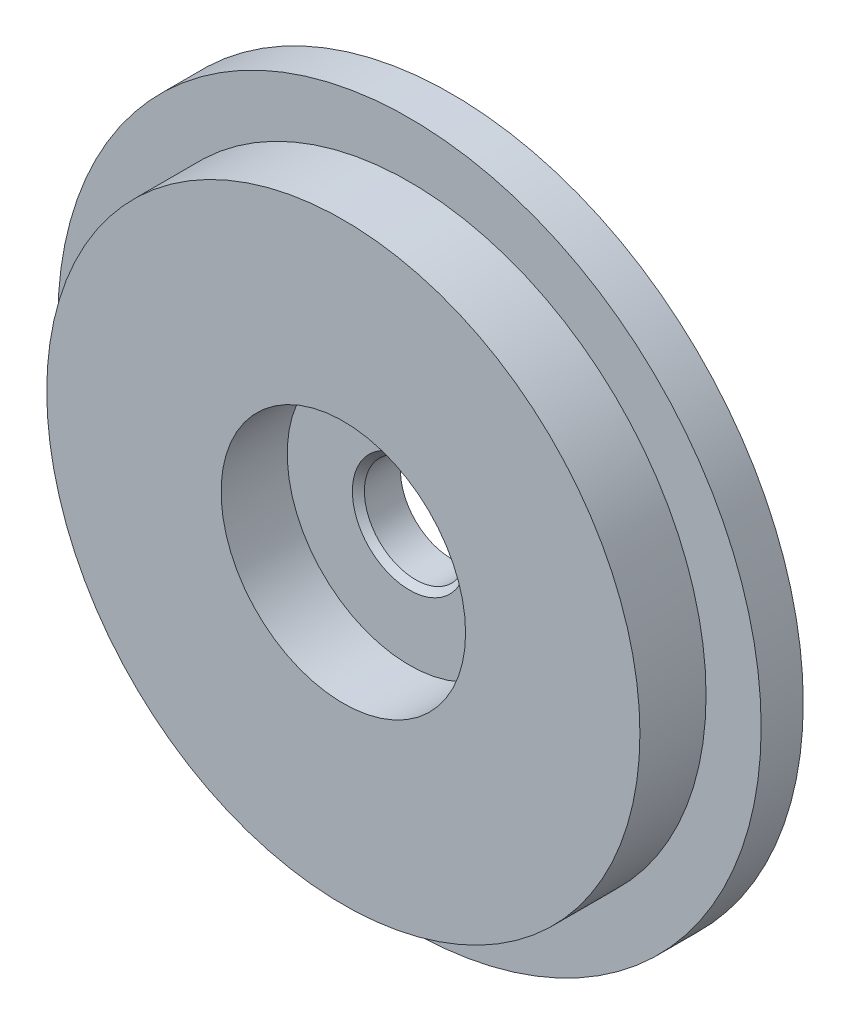
from build123d import *

# Parameters (mm, degrees)
SKETCH_1_R          = 17.55
EXTRUDE_1_DEPTH     = 2.1
EXTRUDE_START       = 2.1
SKETCH_2_R          = 14.8
SKETCH_2_R_2        = 6.1
EXTRUDE_2_DEPTH     = 3.3
CUT_EXTRUDE_1_REACH = 7.4
SKETCH_3_R          = 2.55
CHAMFER_1_SIZE      = 0.3


with BuildPart() as part:
    # 草图1 → 凸台-拉伸1 (new body)
    with BuildSketch(Plane.XY):
        Circle(SKETCH_1_R)
    extrude(amount=EXTRUDE_1_DEPTH)

    # 草图2 → 凸台-拉伸2 (add)
    with BuildSketch(Plane.XY.offset(EXTRUDE_START)):
        Circle(SKETCH_2_R)
        Circle(SKETCH_2_R_2, mode=Mode.SUBTRACT)
    extrude(amount=EXTRUDE_2_DEPTH)

    # 草图3 → 切除-拉伸1 (cut, up to next)
    with BuildSketch(Plane.XY, mode=Mode.PRIVATE) as cut_extrude_1_sk1:
        Circle(SKETCH_3_R)
    cut_extrude_1_tool1 = extrude(cut_extrude_1_sk1.sketch, amount=CUT_EXTRUDE_1_REACH, mode=Mode.PRIVATE) & part.part
    add(cut_extrude_1_tool1.solids().sort_by_distance((0, 0, 0))[0], mode=Mode.SUBTRACT)

    # 倒角1
    chamfer_1_edges = [part.edges().sort_by_distance(p)[0] for p in [
        (-2.55, 0, 2.1),
    ]]
    chamfer(chamfer_1_edges, length=CHAMFER_1_SIZE)


solid = part.part
